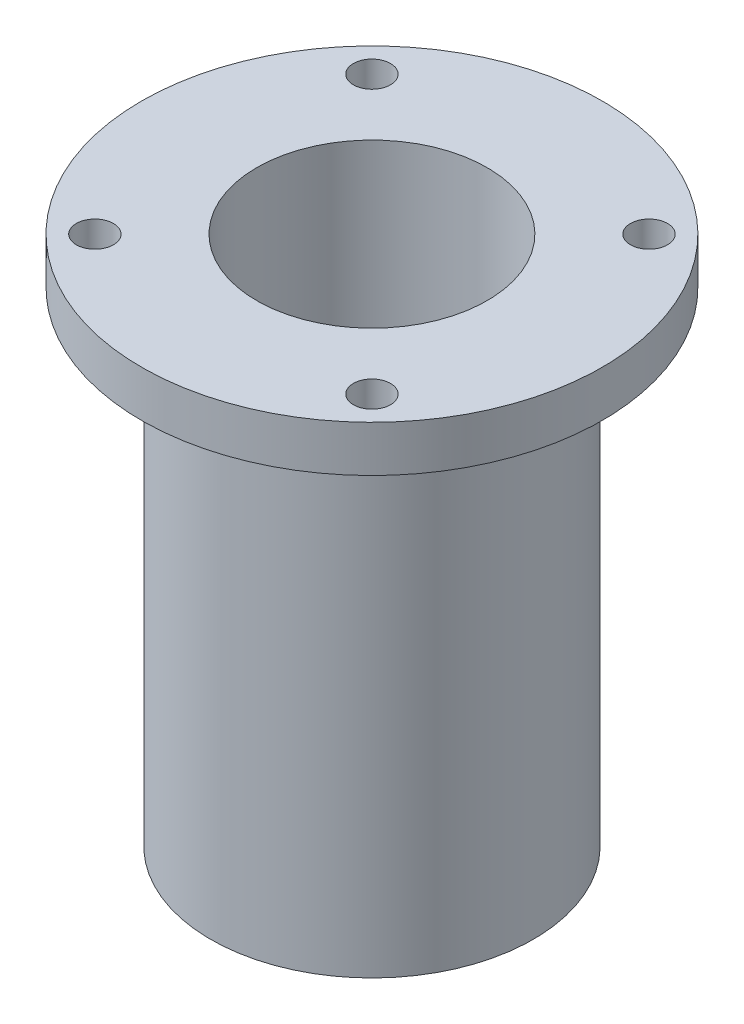
from build123d import *

# Parameters (mm, degrees)
PIPE_TAP_DRILL_FOR_3_8_TAP1_D     = 14.2748
PIPE_TAP_DRILL_FOR_3_8_TAP1_DEPTH = 25.4
PIPE_TAP_DRILL_FOR_3_8_TAP1_TIP   = 4.288582582
CIRPATTERN1_COUNT                 = 4


with BuildPart() as part:
    # Sketch1 → Revolve1 (revolve)
    with BuildSketch(Plane.XY):
        Polygon((-31.75, 0), (-15.875, 0), (-15.875, -63.5), (0, -63.5), (0, -73.025), (-22.225, -73.025), (-22.225, -6.35), (-31.75, -6.35), align=None)
    revolve(axis=Axis((0, 0, 0), (0, -1, 0)))

    # Pipe Tap Drill for 3/8 Tap1
    with Locations(Plane(origin=(0, -73.025, 0), x_dir=(-1, 0, 0), z_dir=(0, -1, 0))):
        with Locations((0, 0)):
            Hole(PIPE_TAP_DRILL_FOR_3_8_TAP1_D / 2, depth=PIPE_TAP_DRILL_FOR_3_8_TAP1_DEPTH)
            with Locations((0, 0, -(PIPE_TAP_DRILL_FOR_3_8_TAP1_DEPTH + PIPE_TAP_DRILL_FOR_3_8_TAP1_TIP / 2))):  # 118° drill point
                Cone(0, PIPE_TAP_DRILL_FOR_3_8_TAP1_D / 2, PIPE_TAP_DRILL_FOR_3_8_TAP1_TIP, mode=Mode.SUBTRACT)

    # Sketch3 → #10 Clearance Hole1 (revolve, cut)
    with BuildSketch(Plane(origin=(19.083044257, 0, -19.083044257), x_dir=(0, 0, 1), z_dir=(1, 0, 0))):
        Polygon((0, 0), (0, 26.933816902), (2.5527, 25.4), (2.5527, 0), align=None)
    f_10_clearance_hole1 = revolve(axis=Axis((19.083044257, 6.35, -19.083044257), (0, -1, 0)), mode=Mode.SUBTRACT)

    # CirPattern1: #10 Clearance Hole1 ×4 about axis
    cirpattern1_axis = Axis((0, 0, 0), (0, 1, 0))
    for i in range(1, CIRPATTERN1_COUNT):
        add(f_10_clearance_hole1.rotate(cirpattern1_axis, i * 360 / CIRPATTERN1_COUNT), mode=Mode.SUBTRACT)


solid = part.part
